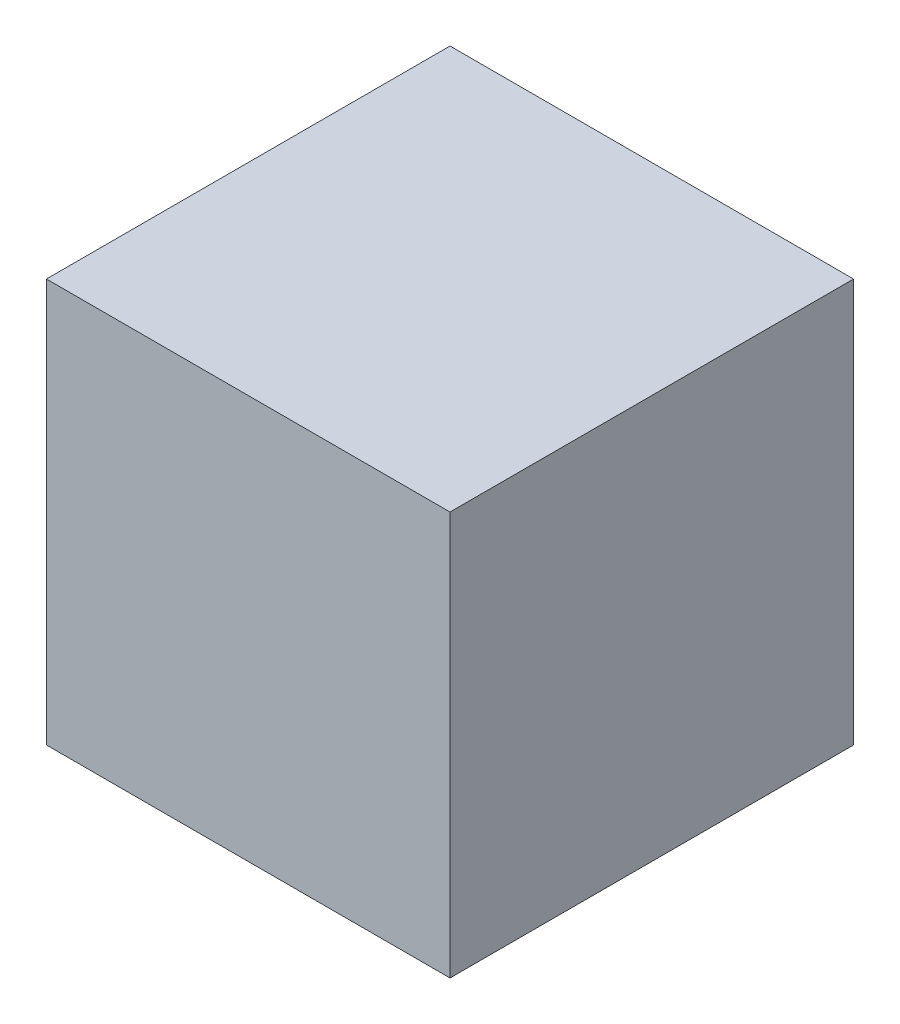
from build123d import *

# Parameters (mm, degrees)
SKETCH1_W           = 152.4
SKETCH1_H           = 152.4
BOSS_EXTRUDE1_DEPTH = 152.4


with BuildPart() as part:
    # Sketch1 → Boss-Extrude1 (new body)
    with BuildSketch(Plane(origin=(0, 0, 0), x_dir=(1, 0, 0), z_dir=(0, 1, 0))):
        Rectangle(SKETCH1_W, SKETCH1_H)
    extrude(amount=BOSS_EXTRUDE1_DEPTH)


solid = part.part
